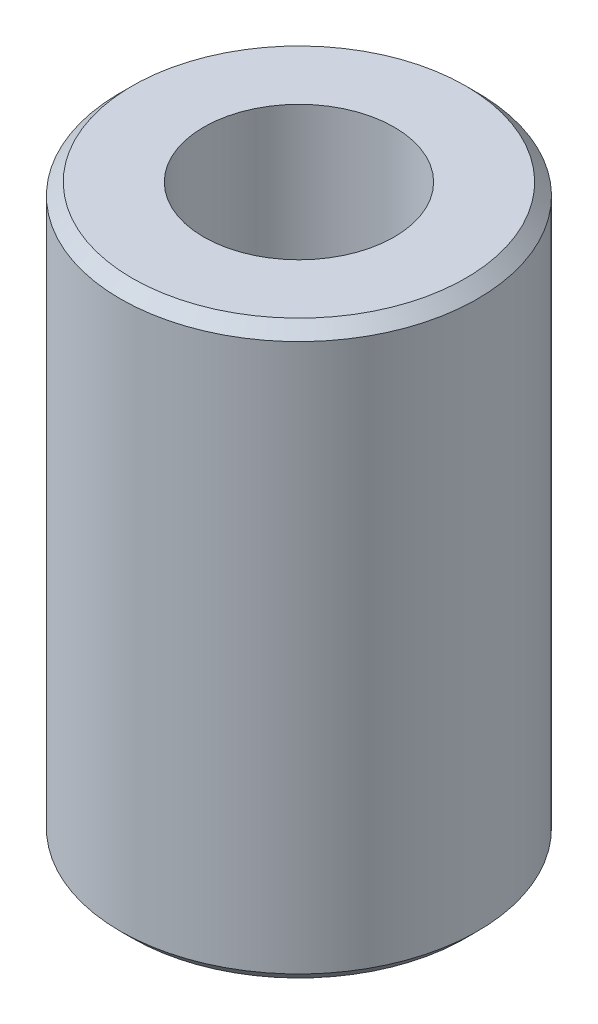
from build123d import *

# Parameters (mm, degrees)
SKETCH1_R           = 7.5
SKETCH1_R_2         = 4
BOSS_EXTRUDE1_DEPTH = 24
CHAMFER1_SIZE       = 0.5


with BuildPart() as part:
    # Sketch1 → Boss-Extrude1 (new body)
    with BuildSketch(Plane(origin=(0, 0, 0), x_dir=(1, 0, 0), z_dir=(0, 1, 0))):
        Circle(SKETCH1_R)
        Circle(SKETCH1_R_2, mode=Mode.SUBTRACT)
    extrude(amount=BOSS_EXTRUDE1_DEPTH)

    # Chamfer1
    chamfer1_edges = [part.edges().sort_by_distance(p)[0] for p in [
        (-7.5, 0, 0),
        (-7.5, 24, 0),
    ]]
    chamfer(chamfer1_edges, length=CHAMFER1_SIZE)


solid = part.part
